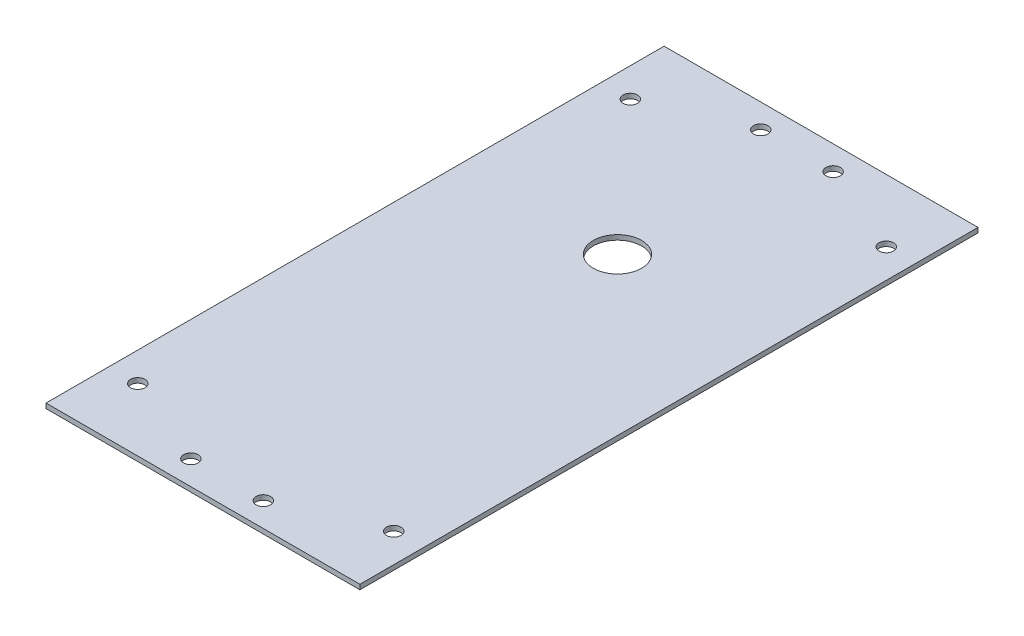
from build123d import *

# Parameters (mm, degrees)
SKETCH_1_W          = 65
SKETCH_1_H          = 128
SKETCH_1_R          = 1.5
EXTRUDE_1_DEPTH     = 1
SKETCH_2_R          = 1.5
CUT_EXTRUDE_1_DEPTH = 2
SKETCH_3_R          = 5
CUT_EXTRUDE_2_DEPTH = 10


with BuildPart() as part:
    # Эскиз1 → Бобышка-Вытянуть1 (new body)
    with BuildSketch(Plane(origin=(0, 0, 0), x_dir=(1, 0, 0), z_dir=(0, 1, 0))):
        with Locations((-41.85845893, -10.35845893)):
            Rectangle(SKETCH_1_W, SKETCH_1_H)
        with Locations((-68.35845893, 40.64154107)):
            Circle(SKETCH_1_R, mode=Mode.SUBTRACT)
        with Locations((-15.35845893, 40.64154107)):
            Circle(SKETCH_1_R, mode=Mode.SUBTRACT)
        with Locations((-15.35845893, -61.35845893)):
            Circle(SKETCH_1_R, mode=Mode.SUBTRACT)
        with Locations((-68.35845893, -61.35845893)):
            Circle(SKETCH_1_R, mode=Mode.SUBTRACT)
    extrude(amount=EXTRUDE_1_DEPTH)

    # Эскиз2 → Вырез-Вытянуть1 (cut, through all)
    with BuildSketch(Plane(origin=(0, 1, 0), x_dir=(1, 0, 0), z_dir=(0, 1, 0))):
        with Locations((-49.35845893, 48.64154107)):
            Circle(SKETCH_2_R)
        with Locations((-34.35845893, 48.64154107)):
            Circle(SKETCH_2_R)
        with Locations((-34.35845893, -69.35845893)):
            Circle(SKETCH_2_R)
        with Locations((-49.35845893, -69.35845893)):
            Circle(SKETCH_2_R)
    extrude(amount=-CUT_EXTRUDE_1_DEPTH, mode=Mode.SUBTRACT)

    # Эскиз3 → Вырез-Вытянуть2 (cut)
    with BuildSketch(Plane(origin=(0, 1, 0), x_dir=(1, 0, 0), z_dir=(0, 1, 0))):
        with Locations((-41.85845893, 11.48154107)):
            Circle(SKETCH_3_R)
    extrude(amount=-CUT_EXTRUDE_2_DEPTH, mode=Mode.SUBTRACT)


solid = part.part
